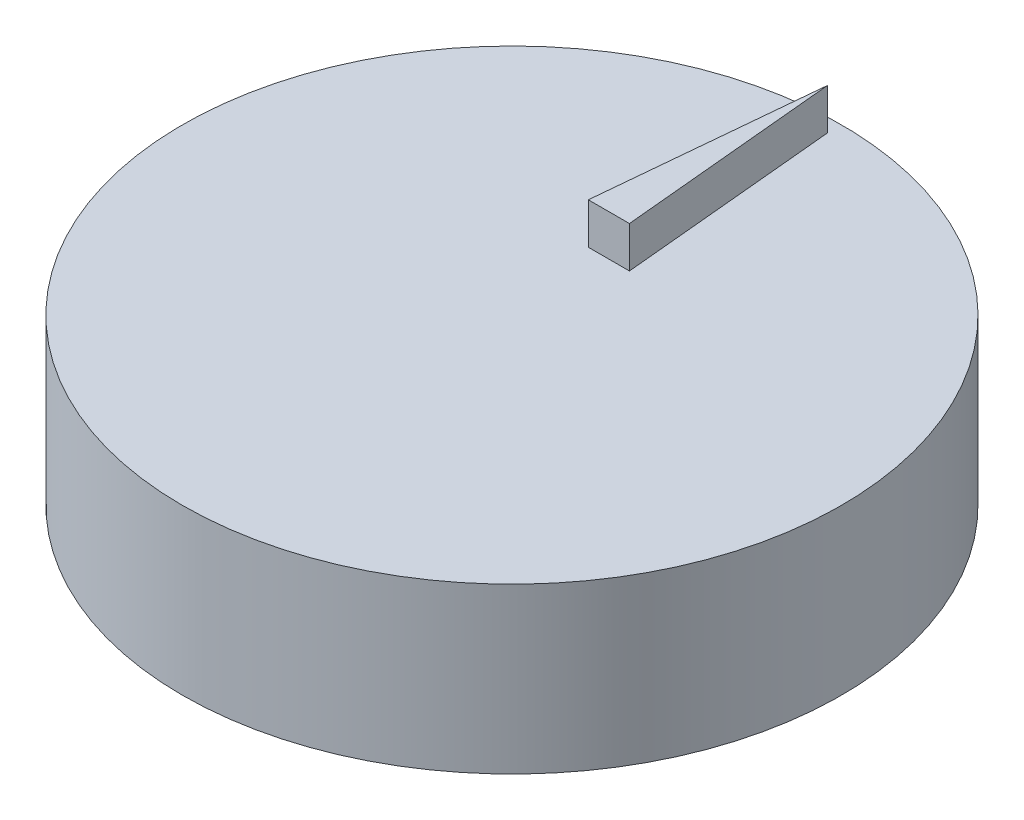
from build123d import *

# Parameters (mm, degrees)
SKETCH2_R           = 40.08124111
BOSS_EXTRUDE2_DEPTH = 20
SKETCH1_W           = 5
SKETCH1_H           = 3
CUT_EXTRUDE1_DEPTH  = 8
BOSS_EXTRUDE3_DEPTH = 5


with BuildPart() as part:
    # Sketch2 → Boss-Extrude2 (new body)
    with BuildSketch(Plane(origin=(0, 0, 0), x_dir=(1, 0, 0), z_dir=(0, 1, 0))):
        with Locations((0, 15)):
            Circle(SKETCH2_R)
    extrude(amount=BOSS_EXTRUDE2_DEPTH)

    # Sketch1 → Cut-Extrude1 (cut)
    with BuildSketch(Plane(origin=(0, 0, 0), x_dir=(1, 0, 0), z_dir=(0, 1, 0))):
        with Locations((0, -4.5)):
            Rectangle(SKETCH1_W, SKETCH1_H)
        with Locations((0, -11.5)):
            Rectangle(SKETCH1_W, SKETCH1_H)
        with Locations((0, 2.5)):
            Rectangle(SKETCH1_W, SKETCH1_H)
        with Locations((0, 9.5)):
            Rectangle(SKETCH1_W, SKETCH1_H)
        with Locations((0, 16.5)):
            Rectangle(SKETCH1_W, SKETCH1_H)
        with Locations((0, 23.5)):
            Rectangle(SKETCH1_W, SKETCH1_H)
    extrude(amount=CUT_EXTRUDE1_DEPTH, mode=Mode.SUBTRACT)

    # Sketch3 → Boss-Extrude3 (add)
    with BuildSketch(Plane(origin=(0, 20, 0), x_dir=(1, 0, 0), z_dir=(0, 1, 0))):
        Polygon((0, 53.367433342), (-2.5, 26.790245023), (2.5, 26.790245023), align=None)
    extrude(amount=BOSS_EXTRUDE3_DEPTH)


solid = part.part
